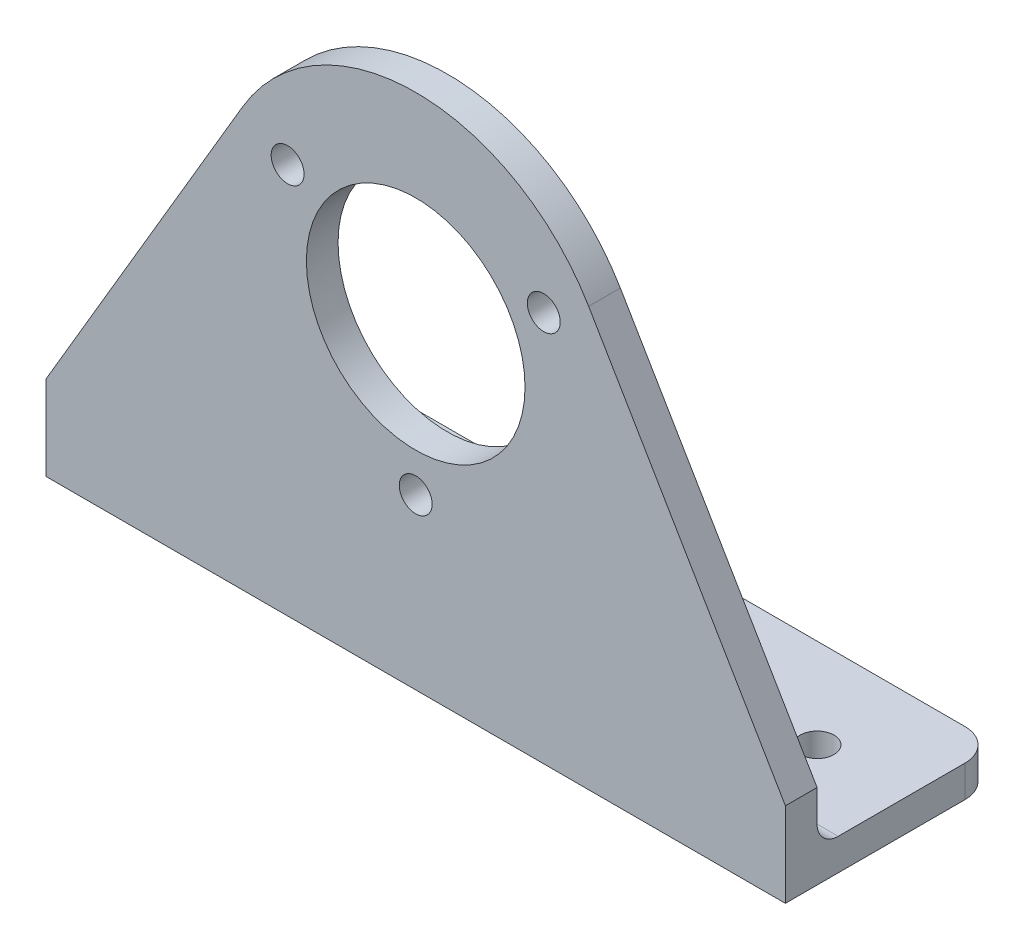
from build123d import *

# Parameters (mm, degrees)
SKETCH1_W           = 70
SKETCH1_H           = 17
BOSS_EXTRUDE1_DEPTH = 3
SKETCH2_R           = 10.35
SKETCH2_R_2         = 1.559144978
BOSS_EXTRUDE2_DEPTH = 3
SKETCH3_R           = 1.6
CUT_EXTRUDE1_DEPTH  = 4
FILLET1_R           = 3
FILLET2_R           = 2


with BuildPart() as part:
    # Sketch1 → Boss-Extrude1 (new body)
    with BuildSketch(Plane(origin=(0, 0, 0), x_dir=(1, 0, 0), z_dir=(0, 1, 0))):
        with Locations((35, 8.5)):
            Rectangle(SKETCH1_W, SKETCH1_H)
    extrude(amount=BOSS_EXTRUDE1_DEPTH)

    # Sketch2 → Boss-Extrude2 (add)
    with BuildSketch(Plane.XY):
        with BuildLine():
            Line((0, 0), (70, 0))
            Line((70, 0), (70, 8))
            Line((70, 8), (51.37327089, 39.639294598))
            ThreePointArc((51.37327089, 39.639294598), (35, 49), (18.62672911, 39.639294598))
            Line((18.62672911, 39.639294598), (0, 8))
            Line((0, 8), (0, 0))
        make_face()
        with Locations((35, 30)):
            Circle(SKETCH2_R, mode=Mode.SUBTRACT)
        with Locations((35, 16)):
            Circle(SKETCH2_R_2, mode=Mode.SUBTRACT)
        with Locations((22.875644347, 37)):
            Circle(SKETCH2_R_2, mode=Mode.SUBTRACT)
        with Locations((47.124355653, 37)):
            Circle(SKETCH2_R_2, mode=Mode.SUBTRACT)
    extrude(amount=BOSS_EXTRUDE2_DEPTH)

    # Sketch3 → Cut-Extrude1 (cut, through all)
    with BuildSketch(Plane(origin=(0, 3, 0), x_dir=(1, 0, 0), z_dir=(0, 1, 0))):
        with Locations(Location((8.5, 8.5, 0), (0, 0, 270))):  # turned: the seam where the file's is
            Circle(SKETCH3_R)
        with Locations(Location((61.5, 8.5, 0), (0, 0, 270))):  # turned: the seam where the file's is
            Circle(SKETCH3_R)
    extrude(amount=-CUT_EXTRUDE1_DEPTH, mode=Mode.SUBTRACT)

    # Fillet1
    fillet1_edges = [part.edges().sort_by_distance(p)[0] for p in [
        (70, 1.5, -17),
        (0, 1.5, -17),
    ]]
    fillet(fillet1_edges, radius=FILLET1_R)

    # Fillet2
    fillet2_edges = [part.edges().sort_by_distance(p)[0] for p in [
        (35, 3, 0),
    ]]
    fillet(fillet2_edges, radius=FILLET2_R)


solid = part.part
